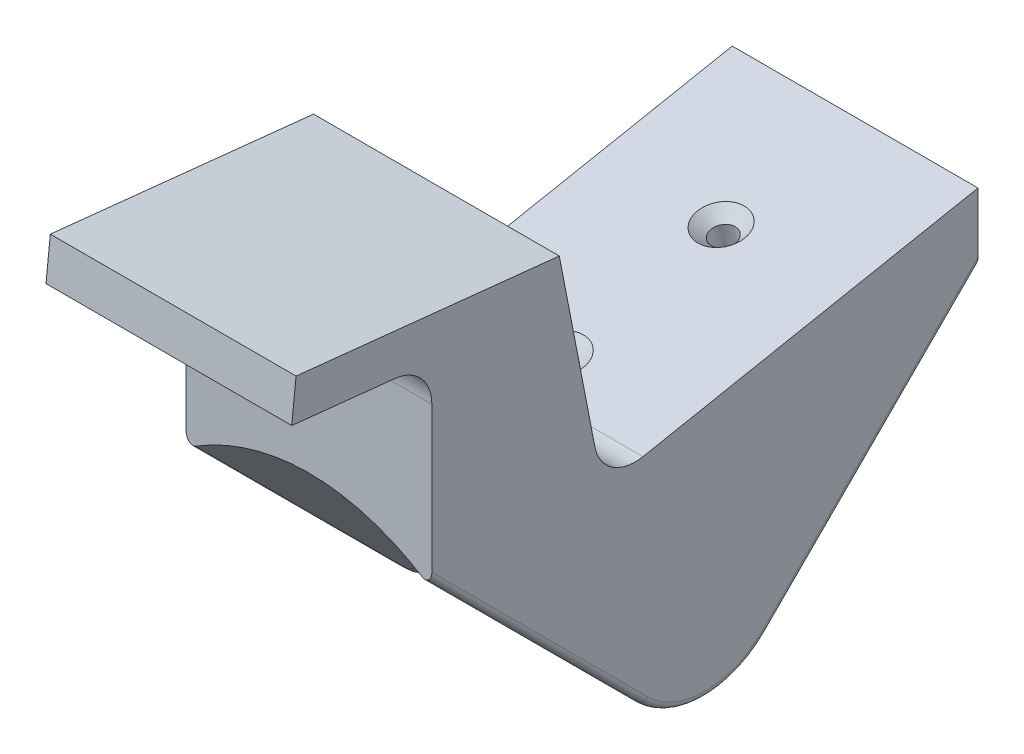
from build123d import *

# Parameters (mm, degrees)
BOSS_EXTRUDE1_DEPTH             = 9
SKETCH4_W                       = 18
SKETCH4_H                       = 44.313566923
CUT_EXTRUDE3_DEPTH              = 6
FILLET1_R                       = 0.5
CUT_EXTRUDE4_DEPTH              = 20
F_2_56_TAPPED_HOLE1_D           = 1.778
F_2_56_TAPPED_HOLE1_DEPTH       = 6.64
F_2_56_TAPPED_HOLE1_CSINK_D     = 3.4544
F_2_56_TAPPED_HOLE1_CSINK_ANGLE = 90
F_2_56_TAPPED_HOLE1_TIP         = 0.53416509
CUT_EXTRUDE5_DEPTH              = 19.0000001
BOSS_EXTRUDE2_DEPTH             = 18
FILLET2_R                       = 3


with BuildPart() as part:
    # Sketch1 → Boss-Extrude1 (new body, symmetric)
    with BuildSketch(Plane(origin=(0, 0, 0), x_dir=(0, 0, -1), z_dir=(1, 0, 0))):
        with BuildLine():
            Line((3.00520382, -3.00520382), (20, 13.98959236))
            Line((20, 13.98959236), (20, 30))
            Line((20, 30), (0, 30))
            Line((0, 30), (0, -4.25))
            ThreePointArc((0, -4.25), (1.626404588, -3.926488013), (3.00520382, -3.00520382))
        make_face()
    extrude(amount=BOSS_EXTRUDE1_DEPTH, both=True)

    # Sweep1: sweep along a path in Sketch2
    with BuildLine(Plane(origin=(0, 0, 0), x_dir=(0, 0, -1), z_dir=(1, 0, 0))) as sweep1_path:
        Line((20, 13.98959236), (3.00520382, -3.00520382))
        ThreePointArc((3.00520382, -3.00520382), (1.626404588, -3.926488013), (0, -4.25))
    # Sketch3 → Sweep1 (sweep)
    with BuildSketch(Plane.XY):
        with BuildLine():
            Line((9, -4.25), (-9, -4.25))
            Line((-9, -4.25), (-9, -6.701215317))
            ThreePointArc((-9, -6.701215317), (0, -4.65), (9, -6.701215317))
            Line((9, -6.701215317), (9, -4.25))
        make_face()
    sweep(path=sweep1_path.line)

    # Sketch4 → Cut-Extrude3 (cut)
    with BuildSketch(Plane(origin=(0, 0, -20), x_dir=(-1, 0, 0), z_dir=(0, 0, -1))):
        with Locations((0, 7.843216539)):
            Rectangle(SKETCH4_W, SKETCH4_H)
    extrude(amount=CUT_EXTRUDE3_DEPTH, mode=Mode.SUBTRACT)

    # Fillet1
    fillet1_edges = [part.edges().sort_by_distance(p)[0] for p in [
        (9, 2.89228781, -12.369237397),
        (-9, 2.89228781, -12.369237397),
        (9, -6.191115675, -2.564444079),
        (-9, -6.191115675, -2.564444079),
    ]]
    fillet(fillet1_edges, radius=FILLET1_R)

    # Mirror1: part across plane


with BuildPart() as part_1:
    add(part.part)
    add(part.part.mirror(Plane(origin=(9, 30, 0), x_dir=(1, 0, 0), z_dir=(0, 0, -1))))

    # Sketch5 → Cut-Extrude4 (cut, symmetric)
    with BuildSketch(Plane(origin=(0, 0, 0), x_dir=(0, 0, -1), z_dir=(1, 0, 0))):
        Polygon((20, 16), (-7.485561137, 10.657348129), (-11.245391787, 30), (20, 30), align=None)
    extrude(amount=CUT_EXTRUDE4_DEPTH, both=True, mode=Mode.SUBTRACT)

    # #2-56 Tapped Hole1
    with Locations(Plane(origin=(0, 11.671404902, 2.268691293), x_dir=(1, 0, 0), z_dir=(0, 0.981627183, 0.190808995))):
        with Locations((0, 12.685487595), (0, 0.685487595)):
            CounterSinkHole(F_2_56_TAPPED_HOLE1_D / 2, F_2_56_TAPPED_HOLE1_CSINK_D / 2, depth=F_2_56_TAPPED_HOLE1_DEPTH, counter_sink_angle=F_2_56_TAPPED_HOLE1_CSINK_ANGLE)
            with Locations((0, 0, -(F_2_56_TAPPED_HOLE1_DEPTH + F_2_56_TAPPED_HOLE1_TIP / 2))):  # 118° drill point
                Cone(0, F_2_56_TAPPED_HOLE1_D / 2, F_2_56_TAPPED_HOLE1_TIP, mode=Mode.SUBTRACT)

    # Sketch8 → Cut-Extrude5 (cut, through all)
    with BuildSketch(Plane.ZY.offset(9)):
        Polygon((10.6659344, 27.018950173), (20, 28), (20, 30), (11.245391787, 30), align=None)
    extrude(amount=-CUT_EXTRUDE5_DEPTH, mode=Mode.SUBTRACT)

    # Sketch10 → Boss-Extrude2 (add)
    with BuildSketch(Plane.ZY.offset(9)):
        Polygon((20, 28), (29.945218954, 29.045284633), (30.258804343, 26.061718947), (20, 24.983475161), align=None)
    extrude(amount=-BOSS_EXTRUDE2_DEPTH)

    # Fillet2
    fillet2_edges = [part_1.edges().sort_by_distance(p)[0] for p in [
        (0, 10.657348129, 7.485561137),
        (0, 24.983475161, 20),
    ]]
    fillet(fillet2_edges, radius=FILLET2_R)


solid = part_1.part
